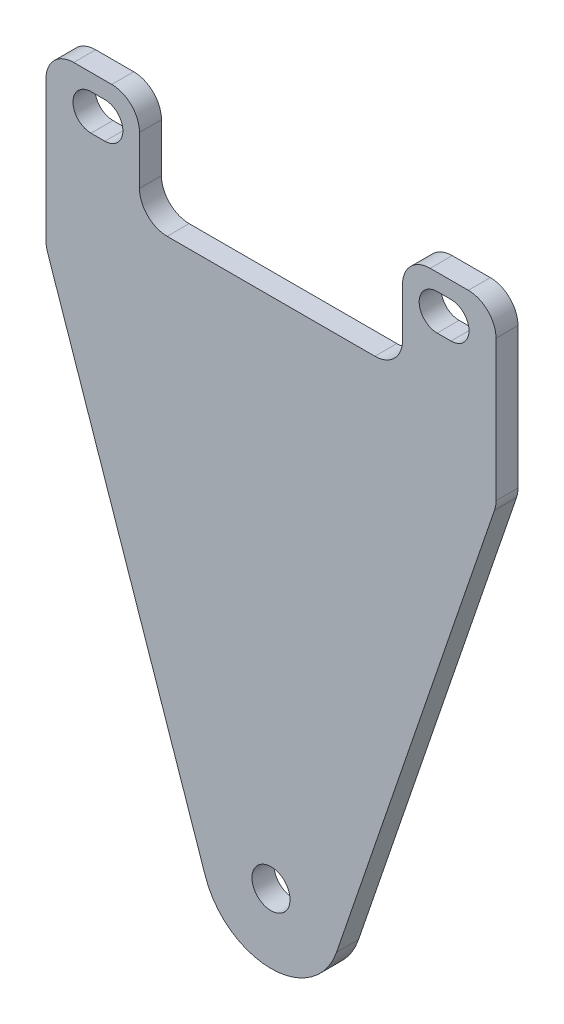
from build123d import *

# Parameters (mm, degrees)
BOSS_EXTRUDE1_DEPTH = 3.175
SKETCH2_W           = 38
SKETCH2_H           = 15
CUT_EXTRUDE1_DEPTH  = 4.175
FILLET1_R           = 4
FILLET2_R           = 10
SKETCH3_R           = 2.75
CUT_EXTRUDE2_DEPTH  = 4.175


with BuildPart() as part:
    # Sketch1 → Boss-Extrude1 (new body)
    with BuildSketch(Plane.XY):
        Polygon((32.5, 120), (-32.5, 120), (-32.5, 95), (0, 0), (32.5, 95), align=None)
    extrude(amount=BOSS_EXTRUDE1_DEPTH)

    # Sketch2 → Cut-Extrude1 (cut, through all)
    with BuildSketch(Plane.XY.offset(3.175)):
        with Locations((0, 112.5)):
            Rectangle(SKETCH2_W, SKETCH2_H)
        with BuildLine():
            Line((-26, 117.6), (-24, 117.6))
            ThreePointArc((-24, 117.6), (-21.4, 115), (-24, 112.4))
            Line((-24, 112.4), (-26, 112.4))
            ThreePointArc((-26, 112.4), (-28.6, 115), (-26, 117.6))
        make_face()
        with BuildLine():
            Line((26, 117.6), (24, 117.6))
            ThreePointArc((24, 117.6), (21.4, 115), (24, 112.4))
            Line((24, 112.4), (26, 112.4))
            ThreePointArc((26, 112.4), (28.6, 115), (26, 117.6))
        make_face()
    extrude(amount=-CUT_EXTRUDE1_DEPTH, mode=Mode.SUBTRACT)

    # Fillet1
    fillet1_edges = [part.edges().sort_by_distance(p)[0] for p in [
        (-19, 105, 1.5875),
        (-19, 120, 1.5875),
        (19, 120, 1.5875),
        (19, 105, 1.5875),
        (-32.5, 95, 1.5875),
        (-32.5, 120, 1.5875),
        (32.5, 120, 1.5875),
        (32.5, 95, 1.5875),
    ]]
    fillet(fillet1_edges, radius=FILLET1_R)

    # Fillet2
    fillet2_edges = [part.edges().sort_by_distance(p)[0] for p in [
        (0, 0, 1.5875),
    ]]
    fillet(fillet2_edges, radius=FILLET2_R)

    # Sketch3 → Cut-Extrude2 (cut, through all)
    with BuildSketch(Plane.XY.offset(3.175)):
        with Locations((0, 30.893977889)):
            Circle(SKETCH3_R)
    extrude(amount=-CUT_EXTRUDE2_DEPTH, mode=Mode.SUBTRACT)


solid = part.part
